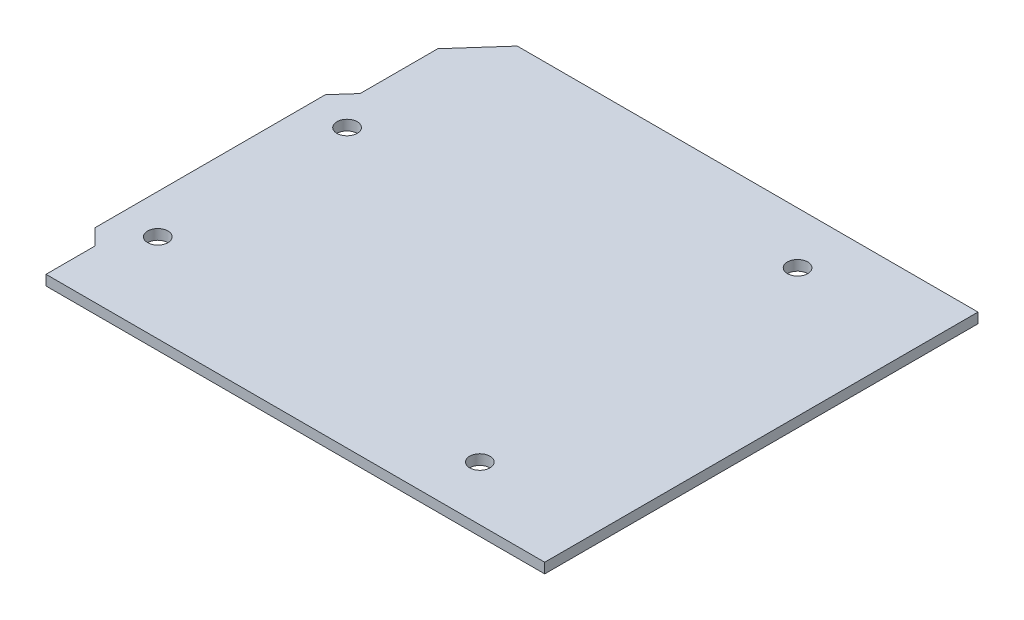
from build123d import *

# Parameters (mm, degrees)
BOSS_EXTRUDE3_DEPTH = 1.5
SKETCH3_R           = 1.5
CUT_EXTRUDE6_DEPTH  = 1.5


with BuildPart() as part:
    # Sketch5 → Boss-Extrude3 (new body)
    with BuildSketch(Plane(origin=(0, 0, 0), x_dir=(1, 0, 0), z_dir=(0, 1, 0))):
        Polygon((-31.936172748, 32.164122013), (-37.46862037, 25.951620882), (-37.46862037, 14.483050574), (-39.885792802, 11.768757102), (-39.885792802, -22.264531804), (-37.547976629, -24.602347977), (-37.547976629, -31.835877987), (-31.61237508, -31.835877987), (36.114207198, -31.835877987), (36.114207198, 32.164122013), align=None)
    extrude(amount=BOSS_EXTRUDE3_DEPTH)

    # Sketch3 → Cut-Extrude6 (cut)
    with BuildSketch(Plane(origin=(0, 0, 0), x_dir=(1, 0, 0), z_dir=(0, 1, 0))):
        with Locations((-34.085940204, 9.171489798)):
            Circle(SKETCH3_R)
        with Locations((-34.085040269, -18.784732287)):
            Circle(SKETCH3_R)
        with Locations((17.126200612, 24.50342873)):
            Circle(SKETCH3_R)
        with Locations((18.50498177, -23.809750535)):
            Circle(SKETCH3_R)
    extrude(amount=CUT_EXTRUDE6_DEPTH, mode=Mode.SUBTRACT)


solid = part.part
